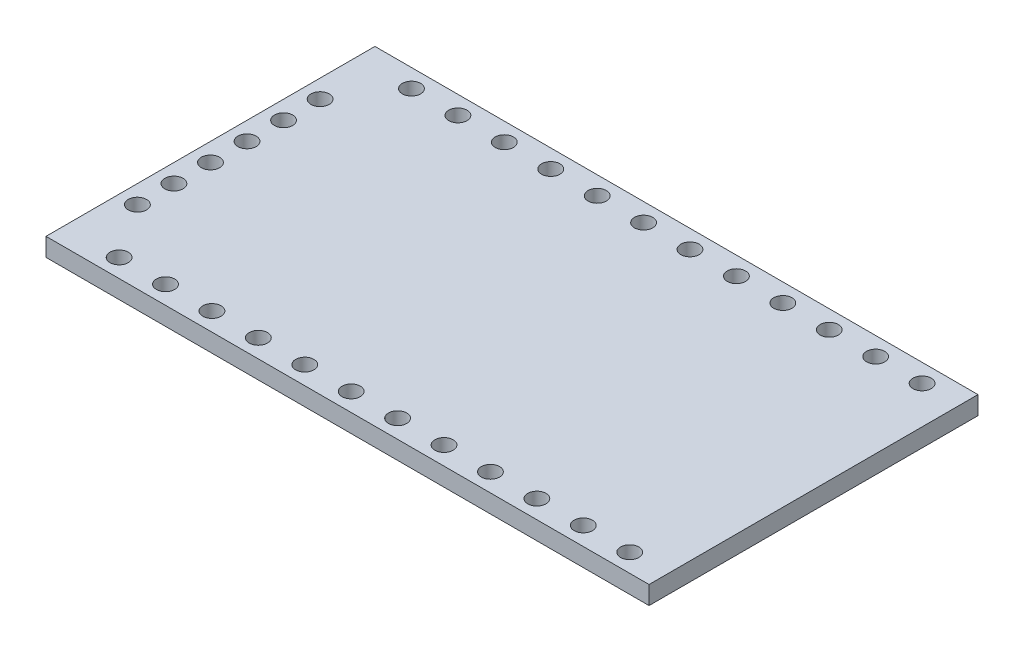
from build123d import *

# Parameters (mm, degrees)
CROQUIS1_W              = 33
CROQUIS1_H              = 18
CROQUIS1_R              = 0.5
SALIENTE_EXTRUIR1_DEPTH = 1


with BuildPart() as part:
    # Croquis1 → Saliente-Extruir1 (new body)
    with BuildSketch(Plane(origin=(0, 0, 0), x_dir=(1, 0, 0), z_dir=(0, 1, 0))):
        with Locations((-7.138495914, 0)):
            Rectangle(CROQUIS1_W, CROQUIS1_H)
        with Locations((-22.638495914, 1)):
            Circle(CROQUIS1_R, mode=Mode.SUBTRACT)
        with Locations((-22.638495914, 3)):
            Circle(CROQUIS1_R, mode=Mode.SUBTRACT)
        with Locations((-22.638495914, 5)):
            Circle(CROQUIS1_R, mode=Mode.SUBTRACT)
        with Locations((-20.638495914, 8)):
            Circle(CROQUIS1_R, mode=Mode.SUBTRACT)
        with Locations((-18.098495914, 8)):
            Circle(CROQUIS1_R, mode=Mode.SUBTRACT)
        with Locations((-15.558495914, 8)):
            Circle(CROQUIS1_R, mode=Mode.SUBTRACT)
        with Locations((-13.018495914, 8)):
            Circle(CROQUIS1_R, mode=Mode.SUBTRACT)
        with Locations((-10.478495914, 8)):
            Circle(CROQUIS1_R, mode=Mode.SUBTRACT)
        with Locations((-7.938495914, 8)):
            Circle(CROQUIS1_R, mode=Mode.SUBTRACT)
        with Locations((-5.398495914, 8)):
            Circle(CROQUIS1_R, mode=Mode.SUBTRACT)
        with Locations((-2.858495914, 8)):
            Circle(CROQUIS1_R, mode=Mode.SUBTRACT)
        with Locations((-0.318495914, 8)):
            Circle(CROQUIS1_R, mode=Mode.SUBTRACT)
        with Locations((2.221504086, 8)):
            Circle(CROQUIS1_R, mode=Mode.SUBTRACT)
        with Locations((4.761504086, 8)):
            Circle(CROQUIS1_R, mode=Mode.SUBTRACT)
        with Locations((7.301504086, 8)):
            Circle(CROQUIS1_R, mode=Mode.SUBTRACT)
        with Locations((7.301504086, -8)):
            Circle(CROQUIS1_R, mode=Mode.SUBTRACT)
        with Locations((4.761504086, -8)):
            Circle(CROQUIS1_R, mode=Mode.SUBTRACT)
        with Locations((2.221504086, -8)):
            Circle(CROQUIS1_R, mode=Mode.SUBTRACT)
        with Locations((-0.318495914, -8)):
            Circle(CROQUIS1_R, mode=Mode.SUBTRACT)
        with Locations((-2.858495914, -8)):
            Circle(CROQUIS1_R, mode=Mode.SUBTRACT)
        with Locations((-5.398495914, -8)):
            Circle(CROQUIS1_R, mode=Mode.SUBTRACT)
        with Locations((-7.938495914, -8)):
            Circle(CROQUIS1_R, mode=Mode.SUBTRACT)
        with Locations((-10.478495914, -8)):
            Circle(CROQUIS1_R, mode=Mode.SUBTRACT)
        with Locations((-13.018495914, -8)):
            Circle(CROQUIS1_R, mode=Mode.SUBTRACT)
        with Locations((-15.558495914, -8)):
            Circle(CROQUIS1_R, mode=Mode.SUBTRACT)
        with Locations((-18.098495914, -8)):
            Circle(CROQUIS1_R, mode=Mode.SUBTRACT)
        with Locations((-20.638495914, -8)):
            Circle(CROQUIS1_R, mode=Mode.SUBTRACT)
        with Locations((-22.638495914, -5)):
            Circle(CROQUIS1_R, mode=Mode.SUBTRACT)
        with Locations((-22.638495914, -3)):
            Circle(CROQUIS1_R, mode=Mode.SUBTRACT)
        with Locations((-22.638495914, -1)):
            Circle(CROQUIS1_R, mode=Mode.SUBTRACT)
    extrude(amount=SALIENTE_EXTRUIR1_DEPTH)


solid = part.part
